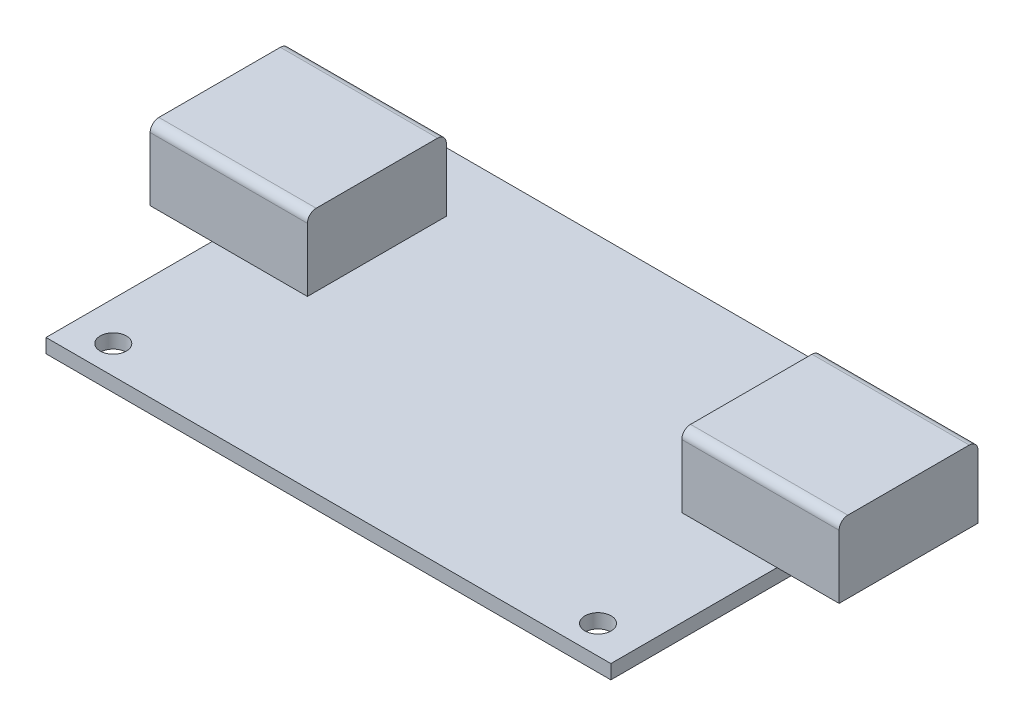
from build123d import *

# Parameters (mm, degrees)
SKETCH1_W            = 64.65
SKETCH1_H            = 41.72
SKETCH1_R            = 1.5
BOSS_EXTRUDE1_DEPTH  = 1.62
SKETCH2_W            = 18
SKETCH2_H            = 15.9
BOSS_EXTRUDE2_DEPTH  = 8.25
FILLET1_R            = 1
FILLET1_OF_MIRROR1_R = 1


with BuildPart() as part:
    # Sketch1 → Boss-Extrude1 (new body)
    with BuildSketch(Plane(origin=(0, 0, 0), x_dir=(1, 0, 0), z_dir=(0, 1, 0))):
        Rectangle(SKETCH1_W, SKETCH1_H)
        with Locations((27.605, -17.61)):
            Circle(SKETCH1_R, mode=Mode.SUBTRACT)
        with Locations((-27.875, -17.61)):
            Circle(SKETCH1_R, mode=Mode.SUBTRACT)
        with Locations((28.875, 17.01)):
            Circle(SKETCH1_R, mode=Mode.SUBTRACT)
        with Locations((-29.325, 17.01)):
            Circle(SKETCH1_R, mode=Mode.SUBTRACT)
    extrude(amount=BOSS_EXTRUDE1_DEPTH)

    # Sketch2 → Boss-Extrude2 (add)
    with BuildSketch(Plane(origin=(0, 1.62, 0), x_dir=(1, 0, 0), z_dir=(0, 1, 0))):
        with Locations((-30.425, 6.11)):
            Rectangle(SKETCH2_W, SKETCH2_H)
    boss_extrude2 = extrude(amount=BOSS_EXTRUDE2_DEPTH)

    # Fillet1
    fillet1_edges = [part.edges().sort_by_distance(p)[0] for p in [
        (-30.425, 9.87, -14.06),
        (-30.425, 9.87, 1.84),
    ]]
    fillet(fillet1_edges, radius=FILLET1_R)

    # Mirror1: Boss-Extrude2 across plane
    add(boss_extrude2.mirror(Plane(origin=(0, 0, 0), x_dir=(0, 0, 1), z_dir=(1, 0, 0))))

    # Fillet1 of Mirror1
    fillet1_of_mirror1_edges = [part.edges().sort_by_distance(p)[0] for p in [
        (30.425, 9.87, -14.06),
        (30.425, 9.87, 1.84),
    ]]
    fillet(fillet1_of_mirror1_edges, radius=FILLET1_OF_MIRROR1_R)


solid = part.part
